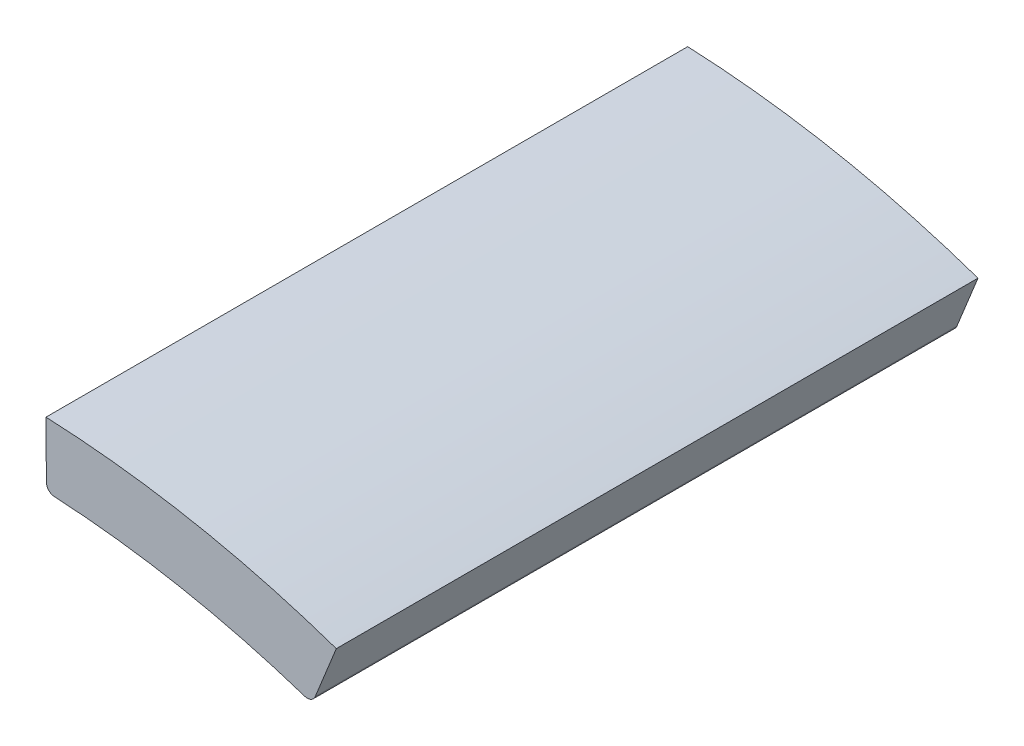
from build123d import *

# Parameters (mm, degrees)
BOSS_EXTRUDE1_DEPTH = 15


with BuildPart() as part:
    # Sketch1 → Boss-Extrude1 (new body)
    with BuildSketch(Plane.XY):
        with BuildLine():
            Line((-99.134442938, 21.769328519), (-98.817115398, 22.553238929))
            Line((-98.817115398, 22.553238929), (-98.754280528, 22.708463115))
            ThreePointArc((-98.754280528, 22.708463115), (-102.100537724, 23.60025606), (-105.54024369, 24.001696896))
            Line((-105.54024369, 24.001696896), (-105.54024369, 23.834302043))
            Line((-105.54024369, 23.834302043), (-105.533426583, 22.988627268))
            Line((-105.533426583, 22.988627268), (-105.531003444, 22.68803248))
            ThreePointArc((-105.531003444, 22.68803248), (-105.475765577, 22.551638114), (-105.342161912, 22.489955815))
            ThreePointArc((-105.342161912, 22.489955815), (-102.381968354, 22.126893501), (-99.495686711, 21.375935169))
            ThreePointArc((-99.495686711, 21.375935169), (-99.34876179, 21.384163954), (-99.247236895, 21.490687852))
            Line((-99.247236895, 21.490687852), (-99.134442938, 21.769328519))
        make_face()
    extrude(amount=-BOSS_EXTRUDE1_DEPTH)


solid = part.part
